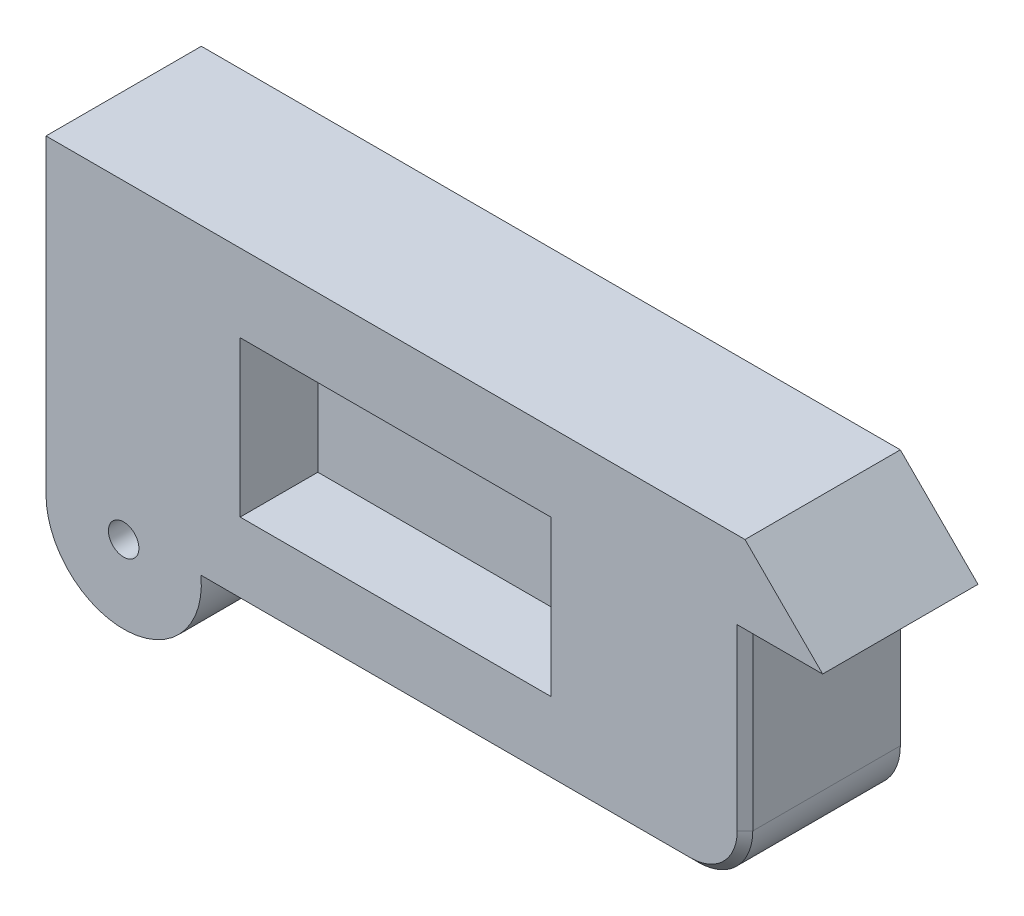
from build123d import *

# Parameters (mm, degrees)
BOSS_EXTRUDE1_DEPTH       = 508
TAP_DRILL_FOR_4_12_TAP1_D = 99.6569
SKETCH8_W                 = 1016
SKETCH8_H                 = 508
CUT_EXTRUDE1_DEPTH        = 254
FILLET1_R                 = 177.8
CHAMFER1_SIZE             = 25.4


with BuildPart() as part:
    # Sketch3 → Boss-Extrude1 (new body)
    with BuildSketch(Plane.XY):
        with BuildLine():
            Line((2286, 762), (2540, 762))
            Line((2540, 762), (2286, 1016))
            Line((2286, 1016), (0, 1016))
            Line((0, 1016), (0, 0))
            ThreePointArc((0, 0), (254, -254), (508, 0))
            Line((508, 0), (2286, 0))
            Line((2286, 0), (2286, 762))
        make_face()
    extrude(amount=BOSS_EXTRUDE1_DEPTH)

    # Tap Drill for 4-12 Tap1 (through all)
    with Locations(Plane(origin=(254, 0, 508), x_dir=(1, 0, 0), z_dir=(0, 0, 1))):
        with Locations((0, 0)):
            Hole(TAP_DRILL_FOR_4_12_TAP1_D / 2)

    # Sketch8 → Cut-Extrude1 (cut)
    with BuildSketch(Plane.XY.offset(508)):
        with Locations((1143, 508)):
            Rectangle(SKETCH8_W, SKETCH8_H)
    extrude(amount=-CUT_EXTRUDE1_DEPTH, mode=Mode.SUBTRACT)

    # Fillet1
    fillet1_edges = [part.edges().sort_by_distance(p)[0] for p in [
        (2286, 0, 254),
    ]]
    fillet(fillet1_edges, radius=FILLET1_R)

    # Chamfer1
    chamfer1_edges = [part.edges().sort_by_distance(p)[0] for p in [
        (2286, 469.9, 508),
        (2233.923585695, 52.076414305, 508),
        (1308.1, 0, 508),
    ]]
    chamfer(chamfer1_edges, length=CHAMFER1_SIZE)


solid = part.part
